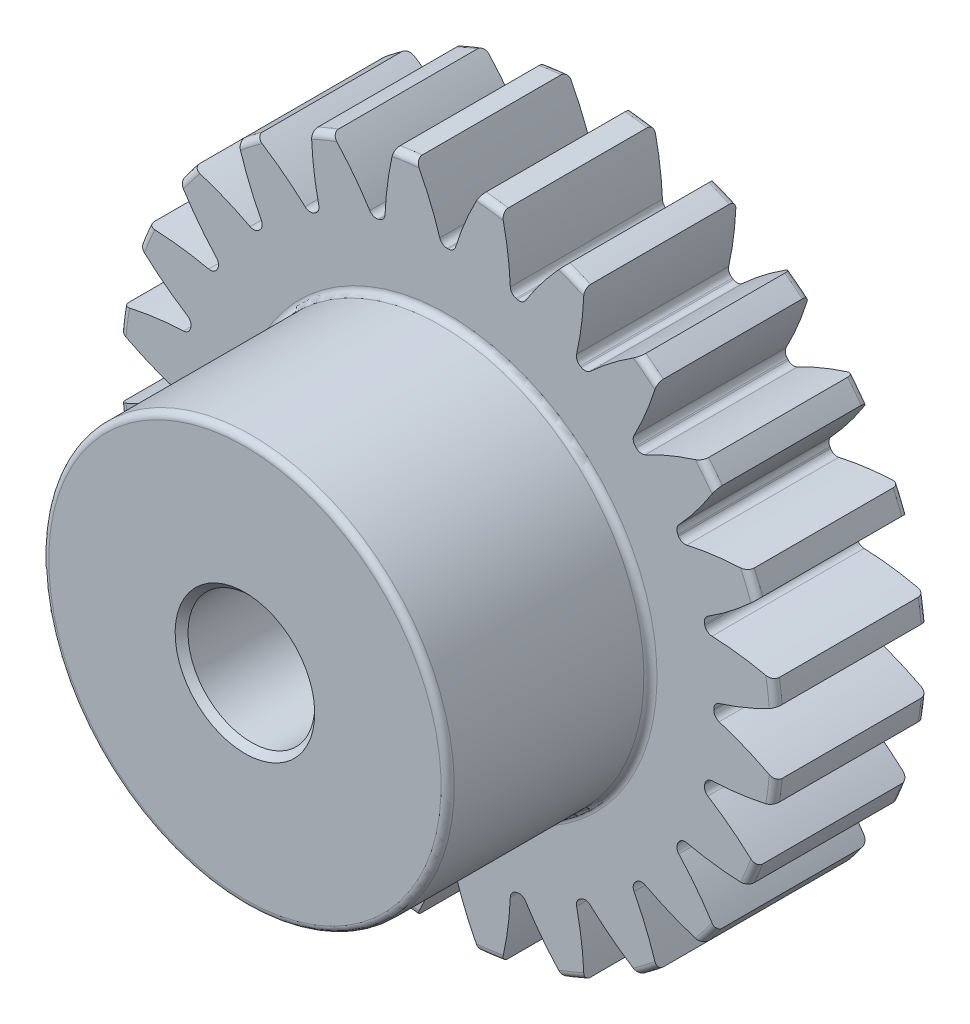
from build123d import *

# Parameters (mm, degrees)
FILLET2_R           = 0.13
CUT_EXTRUDE2_DEPTH  = 4
CIRPATTERN1_COUNT   = 24
SKETCH9_R           = 2
SKETCH9_R_2         = 1.25000004
BOSS_EXTRUDE1_DEPTH = 7
CHAMFER1_SIZE       = 0.127


with BuildPart() as part:
    # Sketch4 → Revolve1 (revolve)
    with BuildSketch(Plane(origin=(0, 0, 0), x_dir=(0, 0, -1), z_dir=(1, 0, 0))):
        Polygon((-7, 2), (-7, 4), (-3, 4), (-3, 6.5), (0, 6.5), (0, 2), align=None)
    revolve(axis=Axis((0, 0, 3), (0, 0, 1)))

    # Fillet2
    fillet2_edges = [part.edges().sort_by_distance(p)[0] for p in [
        (0, -6.5, 0),
        (0, -6.5, 3),
        (0, -4, 3),
        (0, -4, 7),
    ]]
    fillet(fillet2_edges, radius=FILLET2_R)

    # Sketch7 → Cut-Extrude2 (cut, through all)
    with BuildSketch(Plane.XY.offset(3)):
        with BuildLine():
            ThreePointArc((-0.012291339, 5.249985612), (0, 5.25), (0.012291339, 5.249985612))
            ThreePointArc((0.012291339, 5.249985612), (0.10141019, 5.279068119), (0.155863571, 5.355375334))
            ThreePointArc((0.155863571, 5.355375334), (0.365213913, 5.92435749), (0.630915262, 6.469307995))
            ThreePointArc((0.630915262, 6.469307995), (0, 6.5), (-0.630915262, 6.469307995))
            ThreePointArc((-0.630915262, 6.469307995), (-0.365213913, 5.92435749), (-0.155863571, 5.355375334))
            ThreePointArc((-0.155863571, 5.355375334), (-0.10141019, 5.279068119), (-0.012291339, 5.249985612))
        make_face()
    cut_extrude2 = extrude(amount=-CUT_EXTRUDE2_DEPTH, mode=Mode.SUBTRACT)

    # CirPattern1: Cut-Extrude2 ×24 about axis
    cirpattern1_axis = Axis((0, 0, 0), (0, 0, 1))
    for i in range(1, CIRPATTERN1_COUNT):
        add(cut_extrude2.rotate(cirpattern1_axis, i * 360 / CIRPATTERN1_COUNT), mode=Mode.SUBTRACT)

    # Sketch9 → Boss-Extrude1 (add)
    with BuildSketch(Plane(origin=(0, 0, 0), x_dir=(-1, 0, 0), z_dir=(0, 0, -1))):
        Circle(SKETCH9_R)
        Circle(SKETCH9_R_2, mode=Mode.SUBTRACT)
    extrude(amount=-BOSS_EXTRUDE1_DEPTH)

    # Chamfer1
    chamfer1_edges = [part.edges().sort_by_distance(p)[0] for p in [
        (1.25000004, 0, 0),
        (1.25000004, 0, 7),
    ]]
    chamfer(chamfer1_edges, length=CHAMFER1_SIZE)


solid = part.part
